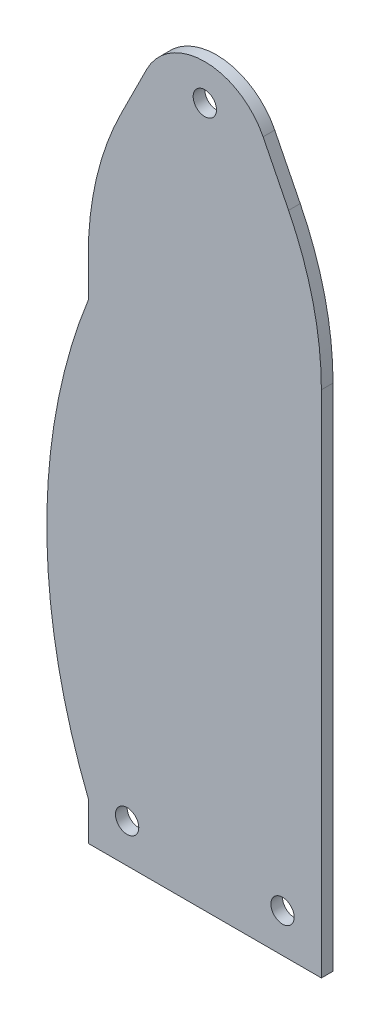
from build123d import *

# Parameters (mm, degrees)
SKETCH_1_R      = 3
EXTRUDE_1_DEPTH = 3


with BuildPart() as part:
    # 草图1 → 凸台-拉伸1 (new body)
    with BuildSketch(Plane.XY):
        with BuildLine():
            Line((8.44582472, 166.89164944), (15, 180))
            ThreePointArc((15, 180), (30, 189.270509831), (45, 180))
            Line((45, 180), (51.55417528, 166.89164944))
            ThreePointArc((51.55417528, 166.89164944), (57.859919157, 149.494795444), (60, 131.1145618))
            Line((60, 131.1145618), (60, 0))
            Line((60, 0), (0, 0))
            Line((0, 0), (0, 10))
            ThreePointArc((0, 10), (-10.668063464, 65.5572809), (0, 121.1145618))
            Line((0, 121.1145618), (0, 131.1145618))
            ThreePointArc((0, 131.1145618), (2.140080843, 149.494795444), (8.44582472, 166.89164944))
        make_face()
        with Locations((50, 10)):
            Circle(SKETCH_1_R, mode=Mode.SUBTRACT)
        with Locations((30, 180)):
            Circle(SKETCH_1_R, mode=Mode.SUBTRACT)
        with Locations((10, 10)):
            Circle(SKETCH_1_R, mode=Mode.SUBTRACT)
    extrude(amount=EXTRUDE_1_DEPTH)


solid = part.part
